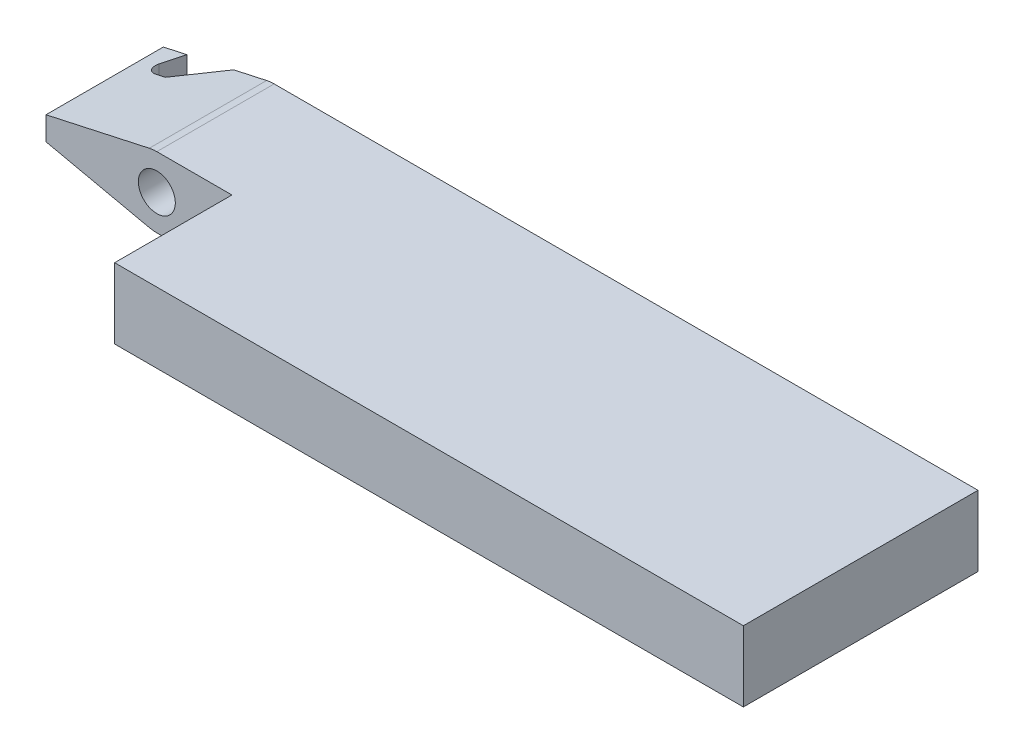
from build123d import *

# Parameters (mm, degrees)
SKETCH1_W           = 38.1
SKETCH1_H           = 12.7
BOSS_EXTRUDE1_DEPTH = 3.81
SKETCH2_W           = 4.064
SKETCH2_H           = 6.35
CUT_EXTRUDE1_DEPTH  = 4.81
SKETCH4_R           = 1
CUT_EXTRUDE2_DEPTH  = 13.7
SKETCH5_R           = 1
BOSS_EXTRUDE2_DEPTH = 6.35
CUT_EXTRUDE3_DEPTH  = 4.81
FILLET1_R           = 0.508


with BuildPart() as part:
    # Sketch1 → Boss-Extrude1 (new body)
    with BuildSketch(Plane(origin=(0, 0, 0), x_dir=(1, 0, 0), z_dir=(0, 1, 0))):
        with Locations((19.05, 6.35)):
            Rectangle(SKETCH1_W, SKETCH1_H)
    extrude(amount=BOSS_EXTRUDE1_DEPTH)

    # Sketch2 → Cut-Extrude1 (cut, through all)
    with BuildSketch(Plane(origin=(0, 3.81, 0), x_dir=(1, 0, 0), z_dir=(0, 1, 0))):
        with Locations((2.032, 3.175)):
            Rectangle(SKETCH2_W, SKETCH2_H)
    extrude(amount=-CUT_EXTRUDE1_DEPTH, mode=Mode.SUBTRACT)

    # Sketch4 → Cut-Extrude2 (cut, through all)
    with BuildSketch(Plane(origin=(0, 0, -12.7), x_dir=(-1, 0, 0), z_dir=(0, 0, -1))):
        with Locations((0, 1.905)):
            Circle(SKETCH4_R)
    extrude(amount=-CUT_EXTRUDE2_DEPTH, mode=Mode.SUBTRACT)

    # Sketch5 → Boss-Extrude2 (add)
    with BuildSketch(Plane(origin=(0, 0, -12.7), x_dir=(-1, 0, 0), z_dir=(0, 0, -1))):
        with BuildLine():
            Line((0.407900981, 3.765817506), (6, 2.54))
            Line((6, 2.54), (6, 1.27))
            Line((6, 1.27), (0.407900981, 0.044182494))
            ThreePointArc((0.407900981, 0.044182494), (-1.905, 1.905), (0.407900981, 3.765817506))
        make_face()
        with Locations((0, 1.905)):
            Circle(SKETCH5_R, mode=Mode.SUBTRACT)
    extrude(amount=-BOSS_EXTRUDE2_DEPTH)

    # Sketch6 → Cut-Extrude3 (cut, through all)
    with BuildSketch(Plane.XZ):
        Polygon((-4.73, -12.7), (-5.377139077, -10.922), (-4.107139077, -10.922), (-2.19, -12.7), align=None)
    extrude(amount=-CUT_EXTRUDE3_DEPTH, mode=Mode.SUBTRACT)

    # Fillet1
    fillet1_edges = [part.edges().sort_by_distance(p)[0] for p in [
        (-5.377139077, 1.905, -10.922),
    ]]
    fillet(fillet1_edges, radius=FILLET1_R)


solid = part.part
